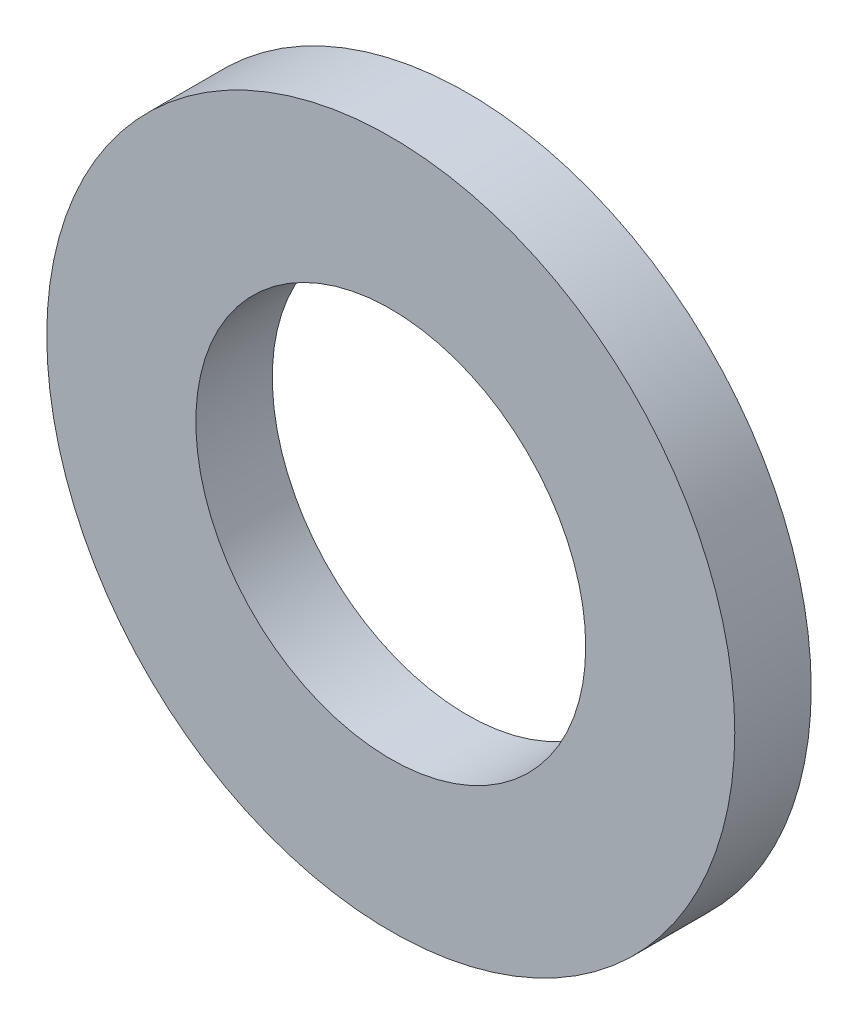
from build123d import *

# Parameters (mm, degrees)
SKETCH1_R           = 9
SKETCH1_R_2         = 5.1
BOSS_EXTRUDE1_DEPTH = 2


with BuildPart() as part:
    # Sketch1 → Boss-Extrude1 (new body)
    with BuildSketch(Plane.XY):
        Circle(SKETCH1_R)
        Circle(SKETCH1_R_2, mode=Mode.SUBTRACT)
    extrude(amount=BOSS_EXTRUDE1_DEPTH)


solid = part.part
